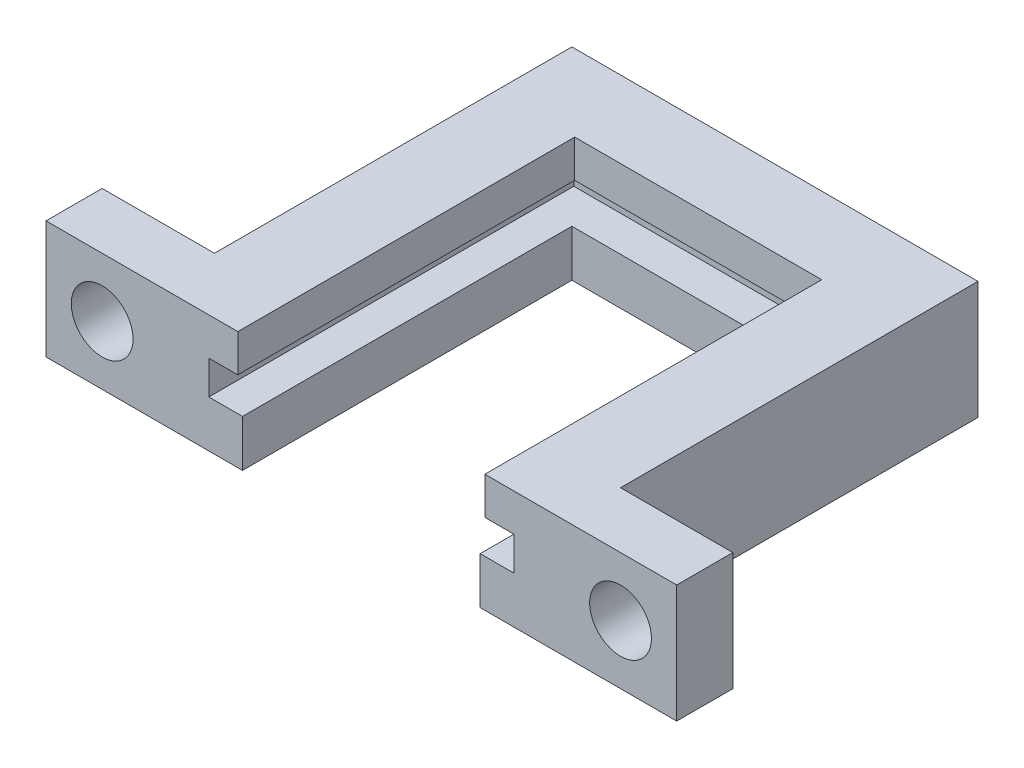
from build123d import *

# Parameters (mm, degrees)
BOSS_EXTRUDE2_DEPTH = 2.5
BOSS_EXTRUDE3_DEPTH = 1.8
BOSS_EXTRUDE4_DEPTH = 2
SKETCH6_W           = 6
SKETCH6_H           = 6.3
SKETCH6_R           = 1.65
BOSS_EXTRUDE6_DEPTH = 3


with BuildPart() as part:
    # Sketch1 → Boss-Extrude2 (new body)
    with BuildSketch(Plane(origin=(0, 0, 0), x_dir=(1, 0, 0), z_dir=(0, 1, 0))):
        Polygon((0, 0), (0, 22.1), (21.7, 22.1), (21.7, 0), (17.2, 0), (17.2, 17.6), (4.5, 17.6), (4.5, 0), align=None)
    extrude(amount=BOSS_EXTRUDE2_DEPTH)

    # Sketch3 → Boss-Extrude3 (add)
    with BuildSketch(Plane(origin=(0, 2.5, 0), x_dir=(1, 0, 0), z_dir=(0, 1, 0))):
        Polygon((0, 0), (0, 22.1), (21.7, 22.1), (21.7, 0), (19, 0), (19, 19.5), (2.7, 19.5), (2.7, 0), align=None)
    extrude(amount=BOSS_EXTRUDE3_DEPTH)

    # Sketch4 → Boss-Extrude4 (add)
    with BuildSketch(Plane(origin=(0, 4.3, 0), x_dir=(1, 0, 0), z_dir=(0, 1, 0))):
        Polygon((0, 0), (0, 22.1), (21.7, 22.1), (21.7, 0), (17.45, 0), (17.45, 18), (4.25, 18), (4.25, 0), align=None)
    extrude(amount=BOSS_EXTRUDE4_DEPTH)

    # Sketch6 → Boss-Extrude6 (add)
    with BuildSketch(Plane.XY):
        with Locations((-3, 3.15)):
            Rectangle(SKETCH6_W, SKETCH6_H)
        with Locations((-3, 3.15)):
            Circle(SKETCH6_R, mode=Mode.SUBTRACT)
        with Locations((24.7, 3.15)):
            Rectangle(SKETCH6_W, SKETCH6_H)
        with Locations((24.7, 3.15)):
            Circle(SKETCH6_R, mode=Mode.SUBTRACT)
    extrude(amount=-BOSS_EXTRUDE6_DEPTH)


solid = part.part
